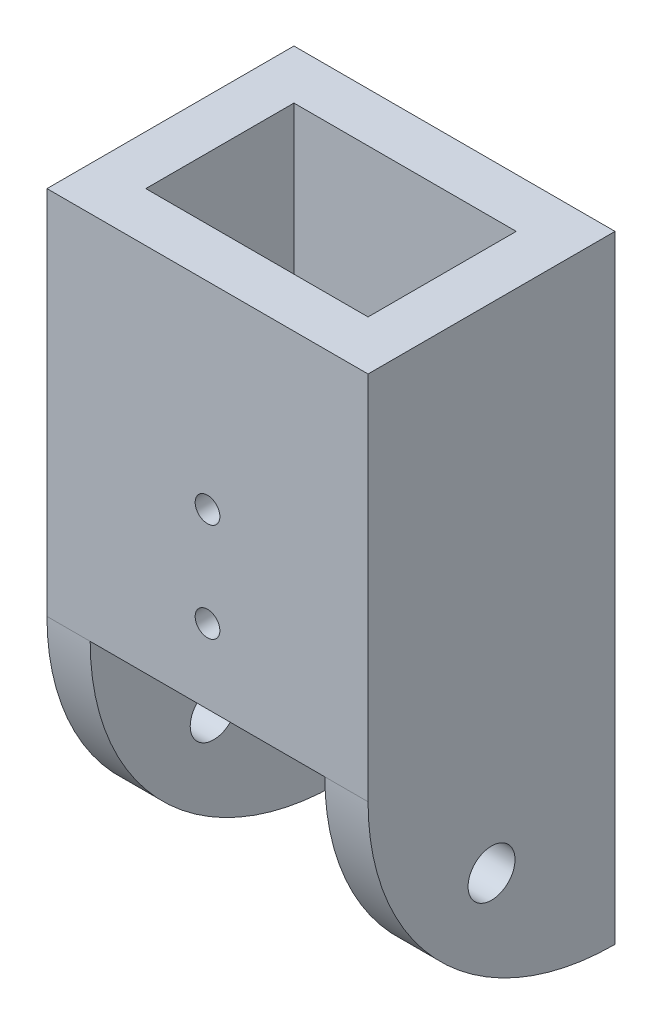
from build123d import *

# Parameters (mm, degrees)
SKETCH1_W               = 13
SKETCH1_H               = 10
SKETCH1_W_2             = 9
SKETCH1_H_2             = 6
BOSS_EXTRUDE1_DEPTH     = 15
BOSS_EXTRUDE2_DEPTH     = 2
SKETCH3_R               = 0.95
CUT_EXTRUDE1_DEPTH      = 14
SKETCH4_R               = 0.5
CUT_EXTRUDE2_DEPTH      = 11
SKETCH5_W               = 0.25
SKETCH5_H               = 10
CUT_EXTRUDE3_DEPTH      = 6
CUT_EXTRUDE3_DEPTH_BACK = 6


with BuildPart() as part:
    # Sketch1 → Boss-Extrude1 (new body)
    with BuildSketch(Plane(origin=(0, 0, 0), x_dir=(1, 0, 0), z_dir=(0, 1, 0))):
        Rectangle(SKETCH1_W, SKETCH1_H)
        Rectangle(SKETCH1_W_2, SKETCH1_H_2, mode=Mode.SUBTRACT)
    extrude(amount=BOSS_EXTRUDE1_DEPTH)

    # Sketch2 → Boss-Extrude2 (add)
    with BuildSketch(Plane(origin=(6.5, 0, 0), x_dir=(0, 0, -1), z_dir=(1, 0, 0))):
        with BuildLine():
            ThreePointArc((-5, 0), (-2.071067812, -7.071067812), (5, -10))
            Line((5, -10), (5, 0))
            Line((5, 0), (-5, 0))
        make_face()
    boss_extrude2 = extrude(amount=-BOSS_EXTRUDE2_DEPTH)

    # Mirror1: Boss-Extrude2 across plane
    add(boss_extrude2.mirror(Plane(origin=(0, 0, 0), x_dir=(0, 0, 1), z_dir=(1, 0, 0))))

    # Sketch3 → Cut-Extrude1 (cut, through all)
    with BuildSketch(Plane(origin=(6.5, 0, 0), x_dir=(0, 0, -1), z_dir=(1, 0, 0))):
        with Locations((0, -5)):
            Circle(SKETCH3_R)
    extrude(amount=-CUT_EXTRUDE1_DEPTH, mode=Mode.SUBTRACT)

    # Sketch4 → Cut-Extrude2 (cut, through all)
    with BuildSketch(Plane.XY.offset(5)):
        with Locations((0, 3)):
            Circle(SKETCH4_R)
        with Locations((0, 7)):
            Circle(SKETCH4_R)
    extrude(amount=-CUT_EXTRUDE2_DEPTH, mode=Mode.SUBTRACT)

    # Sketch5 → Cut-Extrude3 (cut, two sides)
    with BuildSketch(Plane.XY) as cut_extrude3_sk:
        with Locations((-4.625, -5)):
            Rectangle(SKETCH5_W, SKETCH5_H)
        with Locations((4.625, -5)):
            Rectangle(SKETCH5_W, SKETCH5_H)
    extrude(amount=CUT_EXTRUDE3_DEPTH, mode=Mode.SUBTRACT)
    extrude(cut_extrude3_sk.sketch, amount=-CUT_EXTRUDE3_DEPTH_BACK, mode=Mode.SUBTRACT)


solid = part.part
